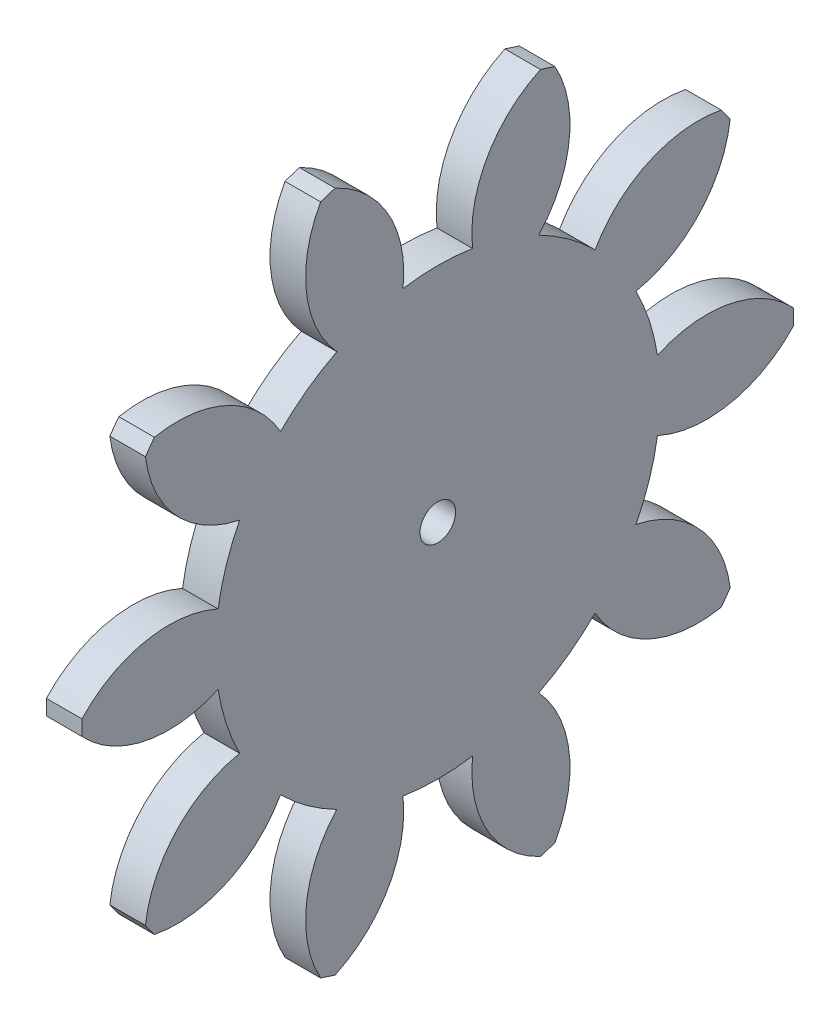
from build123d import *

# Parameters (mm, degrees)
BASPROSKE_W     = 3
BASPROSKE_H     = 30
TOOTHCUT_DEPTH  = 43.532340636
TEETHCUTS_COUNT = 10
TEETHCUTS_ANGLE = 324
BORSKE_R        = 1.5
BORE_DEPTH      = 50.0000508


with BuildPart() as part:
    # BasProSke → Base-Revolve (revolve)
    with BuildSketch(Plane(origin=(0, 0, 0), x_dir=(1, 0, 0), z_dir=(0, 1, 0)), mode=Mode.PRIVATE) as base_revolve_sk:
        with Locations((1.5, 15)):
            Rectangle(BASPROSKE_W, BASPROSKE_H)
    revolve(base_revolve_sk.sketch.rotate(Axis((-10, 0, 0), (1, 0, 0)), 180), axis=Axis((-10, 0, 0), (1, 0, 0)))

    # TooCutSke → ToothCut (cut, through all)
    with BuildSketch(Plane(origin=(0, 0, 0), x_dir=(0, 0, -1), z_dir=(1, 0, 0))):
        with BuildLine():
            ThreePointArc((2.93332476, 18.51811564), (0, 18.749), (-2.93332476, 18.51811564))
            ThreePointArc((-2.93332476, 18.51811564), (-4.155816835, 24.562157762), (-8.691330358, 28.739962104))
            ThreePointArc((-8.691330358, 28.739962104), (0, 30.0254), (8.691330358, 28.739962104))
            ThreePointArc((8.691330358, 28.739962104), (4.155816835, 24.562157762), (2.93332476, 18.51811564))
        make_face()
    toothcut = extrude(amount=TOOTHCUT_DEPTH, mode=Mode.SUBTRACT)

    # TeethCuts: ToothCut ×10 about axis
    teethcuts_axis = Axis((-10, 0, 0), (1, 0, 0))
    for i in range(1, TEETHCUTS_COUNT):
        add(toothcut.rotate(teethcuts_axis, i * TEETHCUTS_ANGLE / (TEETHCUTS_COUNT - 1)), mode=Mode.SUBTRACT)

    # BorSke → Bore (cut, symmetric)
    with BuildSketch(Plane(origin=(0, 0, 0), x_dir=(0, 0, -1), z_dir=(1, 0, 0))):
        with Locations(Location((0, 0, 0), (0, 0, 180))):
            Circle(BORSKE_R)
    extrude(amount=BORE_DEPTH, both=True, mode=Mode.SUBTRACT)


solid = part.part
